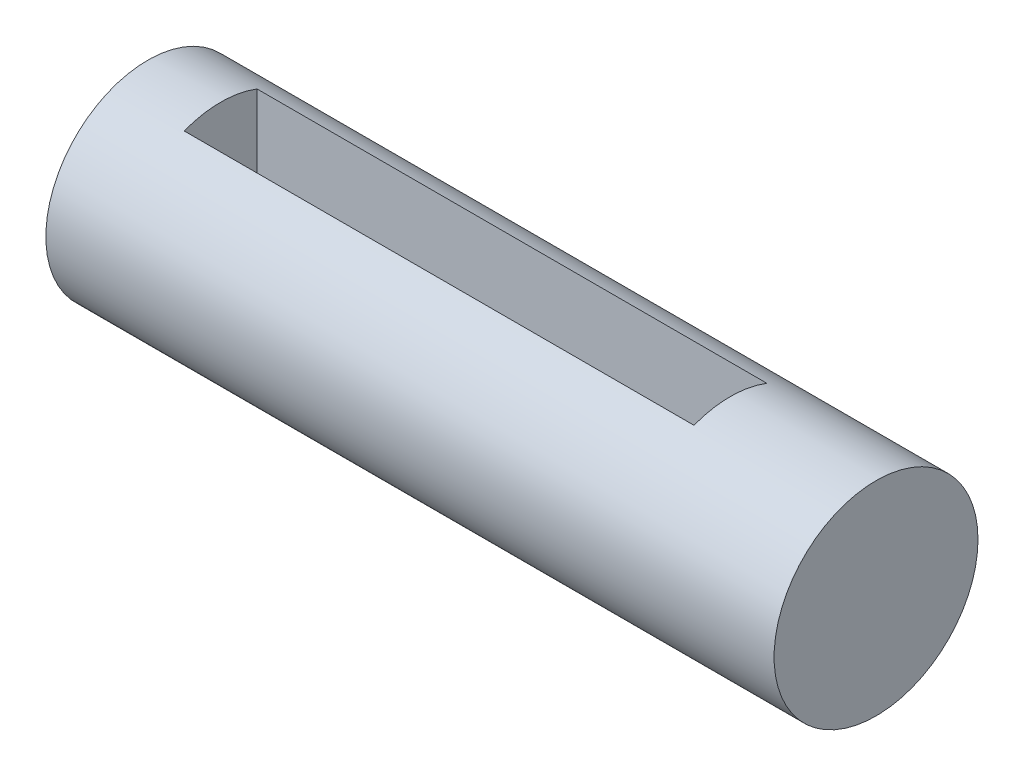
from build123d import *

# Parameters (mm, degrees)
SKETCH1_R           = 7
BOSS_EXTRUDE1_DEPTH = 50
SKETCH2_W           = 35
SKETCH2_H           = 14
CUT_EXTRUDE1_DEPTH  = 2.5


with BuildPart() as part:
    # Sketch1 → Boss-Extrude1 (new body)
    with BuildSketch(Plane(origin=(0, 0, 0), x_dir=(0, 0, -1), z_dir=(1, 0, 0))):
        Circle(SKETCH1_R)
    extrude(amount=BOSS_EXTRUDE1_DEPTH)

    # Sketch2 → Cut-Extrude1 (cut, symmetric)
    with BuildSketch(Plane.XY):
        with Locations((22.5, 0)):
            Rectangle(SKETCH2_W, SKETCH2_H)
    extrude(amount=CUT_EXTRUDE1_DEPTH, both=True, mode=Mode.SUBTRACT)


solid = part.part
